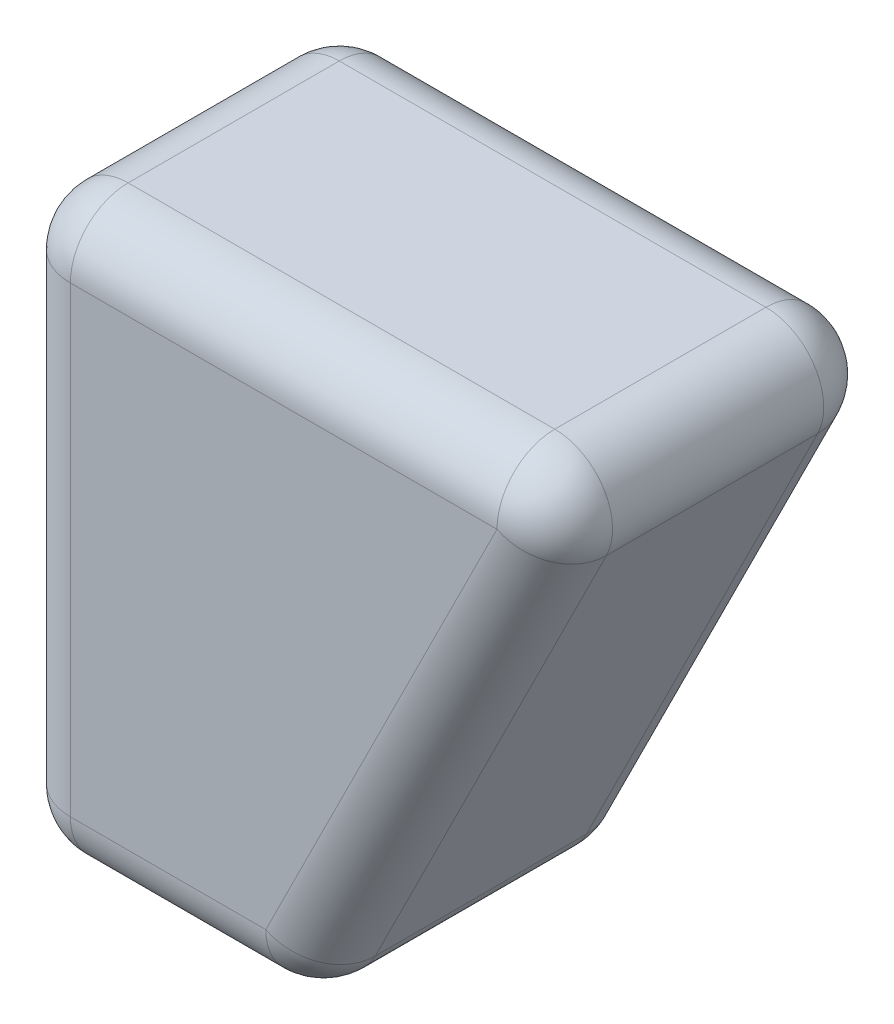
from build123d import *

# Parameters (mm, degrees)
BOSS_EXTRU_1_DEPTH = 56.536328
CONG_1_R           = 10


with BuildPart() as part:
    # Esquisse1 → Boss.-Extru.1 (new body)
    with BuildSketch(Plane.XY):
        Polygon((50, -69.229205607), (100, 30.770794393), (0, 30.770794393), (0, -69.229205607), align=None)
    extrude(amount=-BOSS_EXTRU_1_DEPTH)

    # Congé1
    cong_1_edges = [part.edges().sort_by_distance(p)[0] for p in [
        (0, -19.229205607, 0),
        (25, -69.229205607, 0),
        (50, 30.770794393, -56.536328),
        (0, 30.770794393, -28.268164),
        (0, -19.229205607, -56.536328),
        (0, -69.229205607, -28.268164),
        (25, -69.229205607, -56.536328),
        (50, -69.229205607, -28.268164),
        (75, -19.229205607, -56.536328),
        (100, 30.770794393, -28.268164),
        (75, -19.229205607, 0),
        (50, 30.770794393, 0),
    ]]
    fillet(cong_1_edges, radius=CONG_1_R)


solid = part.part
